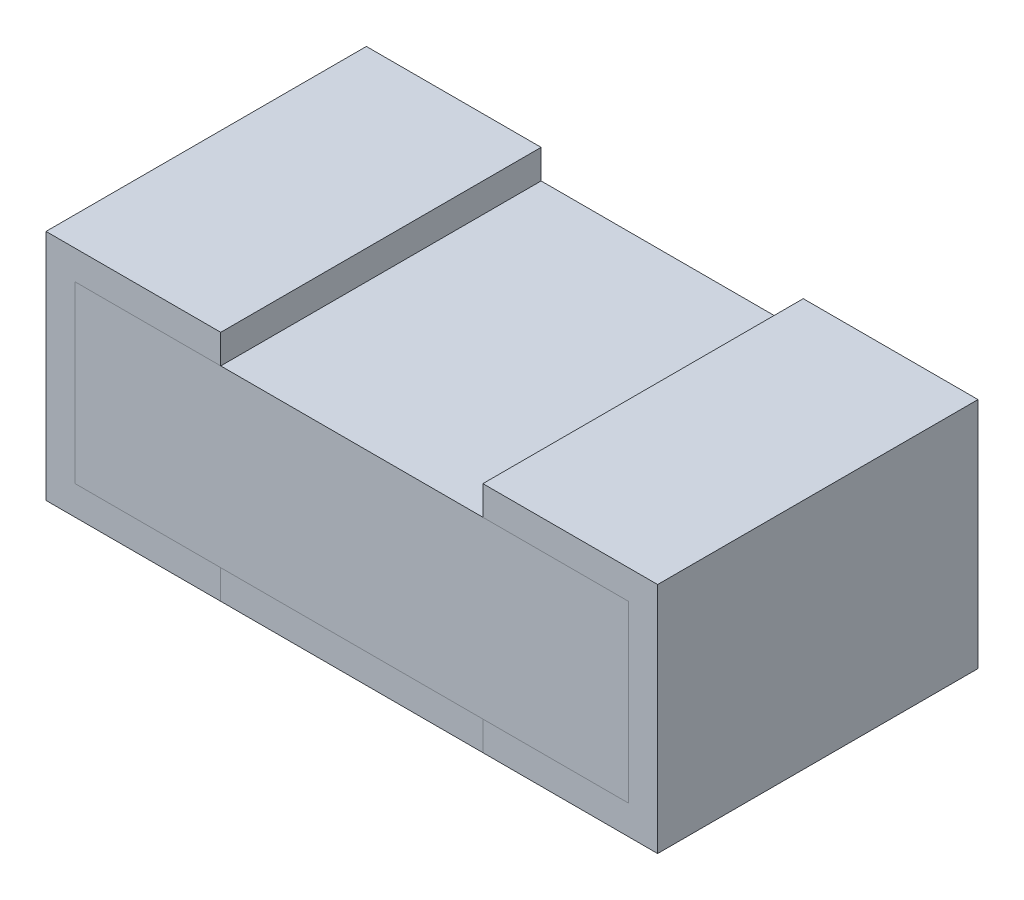
from build123d import *

# Parameters (mm, degrees)
DODANIE_WYCI_GNI_CIE1_DEPTH   = 0.55
DODANIE_WYCI_GNI_CIE1_2_DEPTH = 0.55
SZKIC2_W                      = 0.45
SZKIC2_H                      = 0.05
DODANIE_WYCI_GNI_CIE2_DEPTH   = 0.55
SZKIC3_W                      = 0.95
SZKIC3_H                      = 0.3
DODANIE_WYCI_GNI_CIE3_DEPTH   = 0.55


with BuildPart() as part:
    # Szkic1 → Dodanie-wyciągnięcie1 (new body)
    with BuildSketch(Plane.XY):
        Polygon((0.3, 0.05), (0.05, 0.05), (0.05, 0.35), (0.3, 0.35), (0.3, 0.4), (0, 0.4), (0, 0), (0.3, 0), align=None)
    extrude(amount=DODANIE_WYCI_GNI_CIE1_DEPTH)


with BuildPart() as body_2:
    # Szkic1 → Dodanie-wyci_gni_cie1 2 (new body)
    with BuildSketch(Plane.XY):
        Polygon((0.75, 0.35), (1, 0.35), (1, 0.05), (0.75, 0.05), (0.75, 0), (1.05, 0), (1.05, 0.4), (0.75, 0.4), align=None)
    extrude(amount=DODANIE_WYCI_GNI_CIE1_2_DEPTH)


with BuildPart() as body_3:
    # Szkic2 → Dodanie-wyciągnięcie2 (new body)
    with BuildSketch(Plane.XY.offset(0.55)):
        with Locations((0.525, 0.025)):
            Rectangle(SZKIC2_W, SZKIC2_H)
    extrude(amount=-DODANIE_WYCI_GNI_CIE2_DEPTH)


with BuildPart() as body_4:
    # Szkic3 → Dodanie-wyciągnięcie3 (new body)
    with BuildSketch(Plane.XY.offset(0.55)):
        with Locations((0.525, 0.2)):
            Rectangle(SZKIC3_W, SZKIC3_H)
    extrude(amount=-DODANIE_WYCI_GNI_CIE3_DEPTH)


solid = Compound([part.part, body_2.part, body_3.part, body_4.part])
